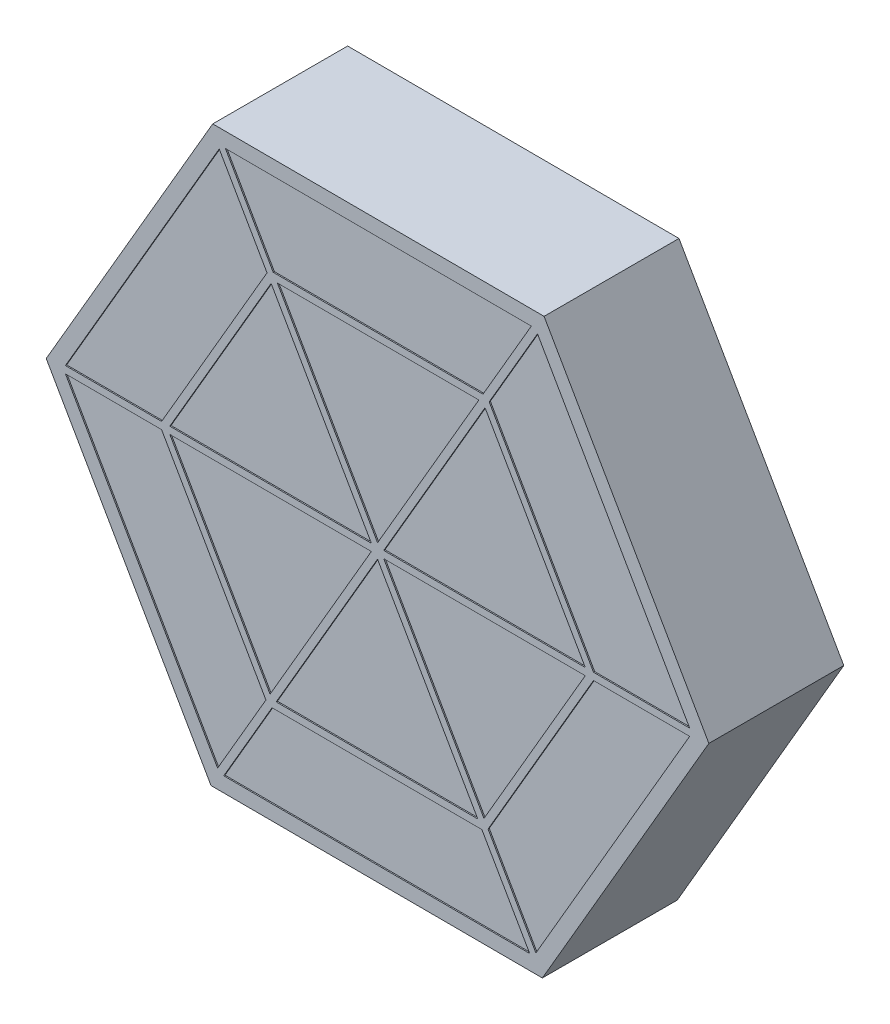
from build123d import *

# Parameters (mm, degrees)
SALIENTE_EXTRUIR1_DEPTH = 40
SALIENTE_EXTRUIR2_DEPTH = 5
SALIENTE_EXTRUIR3_DEPTH = 0.4


with BuildPart() as part:
    # Croquis1 → Saliente-Extruir1 (new body)
    with BuildSketch(Plane.XY):
        Polygon((-55.463005259, 96.735362128), (-111.506783676, 0.33530954), (-56.043778418, -96.400052588), (55.463005259, -96.735362128), (111.506783676, -0.33530954), (56.043778418, 96.400052588), align=None)
        Polygon((53.766067764, 92.51110391), (-53.233932236, 92.8183325), (-107, 0.30722859), (-53.766067764, -92.51110391), (53.233932236, -92.8183325), (107, -0.30722859), align=None, mode=Mode.SUBTRACT)
    extrude(amount=SALIENTE_EXTRUIR1_DEPTH)

    # Croquis2 → Saliente-Extruir2 (add)
    with BuildSketch(Plane.XY.offset(40)):
        Polygon((111.506783676, -0.33530954), (56.043778418, 96.400052588), (-55.463005259, 96.735362128), (-111.506783676, 0.33530954), (-56.043778418, -96.400052588), (55.463005259, -96.735362128), align=None)
    extrude(amount=SALIENTE_EXTRUIR2_DEPTH)

    # Croquis4 → Saliente-Extruir3 (add)
    with BuildSketch(Plane.XY.offset(45)):
        Polygon((-56.159430926, 95.537450908), (-110.810358009, 1.533220759), (-105.03688142, 1.515859468), (-53.287727951, 90.528792869), align=None)
        Polygon((-111.506783676, 0.33530954), (-110.817574962, -0.86676839), (-105.044098374, -0.884129681), (-105.733307088, 0.317948248), (-105.03688142, 1.515859468), (-110.810358009, 1.533220759), align=None)
        Polygon((-105.044098374, -0.884129681), (-110.817574962, -0.86676839), (-56.732987132, -95.197974658), (-53.831213518, -90.20667791), align=None)
        Polygon((-105.733307088, 0.317948248), (-105.044098374, -0.884129681), (-72.68406869, -0.981438798), (-73.373277404, 0.220639131), (-72.676851737, 1.418550351), (-105.03688142, 1.515859468), align=None)
        Polygon((-55.463005259, 96.735362128), (-56.159430926, 95.537450908), (-53.287727951, 90.528792869), (-52.591302284, 91.726704088), (-51.205667902, 91.722537378), (-54.077370877, 96.731195418), align=None)
        Polygon((54.658144036, 96.404219298), (-54.077370877, 96.731195418), (-51.205667902, 91.722537378), (51.756370423, 91.41292255), align=None)
        Polygon((-52.591302284, 91.726704088), (-53.287727951, 90.528792869), (-37.191985277, 62.455530537), (-36.495559609, 63.653441757), (-35.109925228, 63.649275047), (-51.205667902, 91.722537378), align=None)
        Polygon((56.043778418, 96.400052588), (54.658144036, 96.404219298), (51.756370423, 91.41292255), (53.142004804, 91.40875584), (53.831213518, 90.20667791), (56.732987132, 95.197974658), align=None)
        Polygon((53.142004804, 91.40875584), (51.756370423, 91.41292255), (35.492083414, 63.436969335), (36.877717795, 63.432802625), (37.566926509, 62.230724696), (53.831213518, 90.20667791), align=None)
        Polygon((110.817574962, 0.86676839), (56.732987132, 95.197974658), (53.831213518, 90.20667791), (105.044098374, 0.884129681), align=None)
        Polygon((72.676851737, -1.418550351), (105.03688142, -1.515859468), (105.733307088, -0.317948248), (105.044098374, 0.884129681), (72.68406869, 0.981438798), (73.373277404, -0.220639131), align=None)
        Polygon((105.03688142, -1.515859468), (110.810358009, -1.533220759), (111.506783676, -0.33530954), (110.817574962, 0.86676839), (105.044098374, 0.884129681), (105.733307088, -0.317948248), align=None)
        Polygon((53.287727951, -90.528792869), (56.159430926, -95.537450908), (110.810358009, -1.533220759), (105.03688142, -1.515859468), align=None)
        Polygon((-53.831213518, -90.20667791), (-56.732987132, -95.197974658), (-56.043778418, -96.400052588), (-54.658144036, -96.404219298), (-51.756370423, -91.41292255), (-53.142004804, -91.40875584), align=None)
        Polygon((-51.756370423, -91.41292255), (-54.658144036, -96.404219298), (54.077370877, -96.731195418), (51.205667902, -91.722537378), align=None)
        Polygon((51.205667902, -91.722537378), (54.077370877, -96.731195418), (55.463005259, -96.735362128), (56.159430926, -95.537450908), (53.287727951, -90.528792869), (52.591302284, -91.726704088), align=None)
        Polygon((35.109925228, -63.649275047), (51.205667902, -91.722537378), (52.591302284, -91.726704088), (53.287727951, -90.528792869), (37.191985277, -62.455530537), (36.495559609, -63.653441757), align=None)
        Polygon((-37.566926509, -62.230724696), (-53.831213518, -90.20667791), (-53.142004804, -91.40875584), (-51.756370423, -91.41292255), (-35.492083414, -63.436969335), (-36.877717795, -63.432802625), align=None)
        Polygon((-36.174075174, -59.834902257), (-37.566926509, -62.230724696), (-36.877717795, -63.432802625), (-35.492083414, -63.436969335), (-34.099232079, -61.041146896), (-35.48486646, -61.036980186), align=None)
        Polygon((-34.099232079, -61.041146896), (-35.492083414, -63.436969335), (35.109925228, -63.649275047), (33.7315078, -61.245119188), align=None)
        Polygon((-69.912799928, -0.989772218), (-72.68406869, -0.981438798), (-37.566926509, -62.230724696), (-36.174075174, -59.834902257), align=None)
        Polygon((33.7315078, -61.245119188), (35.109925228, -63.649275047), (36.495559609, -63.653441757), (37.191985277, -62.455530537), (35.813567849, -60.051374678), (35.117142181, -61.249285898), align=None)
        Polygon((2.074843095, -1.206244639), (0.689208714, -1.20207793), (-0.007216953, -2.399989149), (33.7315078, -61.245119188), (35.117142181, -61.249285898), (35.813567849, -60.051374678), align=None)
        Polygon((-0.696425667, -1.19791122), (-2.082060049, -1.19374451), (-36.174075174, -59.834902257), (-35.48486646, -61.036980186), (-34.099232079, -61.041146896), (-0.007216953, -2.399989149), align=None)
        Polygon((72.676851737, -1.418550351), (69.905582974, -1.410216931), (35.813567849, -60.051374678), (37.191985277, -62.455530537), align=None)
        Polygon((70.602008642, -0.212305711), (69.905582974, -1.410216931), (72.676851737, -1.418550351), (73.373277404, -0.220639131), (72.68406869, 0.981438798), (69.912799928, 0.989772218), align=None)
        Polygon((36.174075174, 59.834902257), (69.912799928, 0.989772218), (72.68406869, 0.981438798), (37.566926509, 62.230724696), align=None)
        Polygon((0.689208714, -1.20207793), (-0.696425667, -1.19791122), (-0.007216953, -2.399989149), align=None)
        Polygon((-1.385634381, 0.00416671), (-2.082060049, -1.19374451), (-0.696425667, -1.19791122), align=None)
        Polygon((-1.385634381, 0.00416671), (-0.696425667, -1.19791122), (0.689208714, -1.20207793), (1.385634381, -0.00416671), (0.696425667, 1.19791122), (-0.689208714, 1.20207793), align=None)
        Polygon((-2.074843095, 1.206244639), (-1.385634381, 0.00416671), (-0.689208714, 1.20207793), align=None)
        Polygon((0.007216953, 2.399989149), (-0.689208714, 1.20207793), (0.696425667, 1.19791122), align=None)
        Polygon((0.696425667, 1.19791122), (1.385634381, -0.00416671), (2.082060049, 1.19374451), align=None)
        Polygon((1.385634381, -0.00416671), (0.689208714, -1.20207793), (2.074843095, -1.206244639), align=None)
        Polygon((1.385634381, -0.00416671), (2.074843095, -1.206244639), (69.905582974, -1.410216931), (70.602008642, -0.212305711), (69.912799928, 0.989772218), (2.082060049, 1.19374451), align=None)
        Polygon((-70.602008642, 0.212305711), (-69.912799928, -0.989772218), (-2.082060049, -1.19374451), (-1.385634381, 0.00416671), (-2.074843095, 1.206244639), (-69.905582974, 1.410216931), align=None)
        Polygon((-35.813567849, 60.051374678), (-2.074843095, 1.206244639), (-0.689208714, 1.20207793), (0.007216953, 2.399989149), (-33.7315078, 61.245119188), (-35.117142181, 61.249285898), align=None)
        Polygon((0.007216953, 2.399989149), (0.696425667, 1.19791122), (2.082060049, 1.19374451), (36.174075174, 59.834902257), (35.48486646, 61.036980186), (34.099232079, 61.041146896), align=None)
        Polygon((35.492083414, 63.436969335), (34.099232079, 61.041146896), (35.48486646, 61.036980186), (36.174075174, 59.834902257), (37.566926509, 62.230724696), (36.877717795, 63.432802625), align=None)
        Polygon((35.492083414, 63.436969335), (-35.109925228, 63.649275047), (-33.7315078, 61.245119188), (34.099232079, 61.041146896), align=None)
        Polygon((-36.495559609, 63.653441757), (-37.191985277, 62.455530537), (-35.813567849, 60.051374678), (-35.117142181, 61.249285898), (-33.7315078, 61.245119188), (-35.109925228, 63.649275047), align=None)
        Polygon((-37.191985277, 62.455530537), (-72.676851737, 1.418550351), (-69.905582974, 1.410216931), (-35.813567849, 60.051374678), align=None)
        Polygon((-73.373277404, 0.220639131), (-72.68406869, -0.981438798), (-69.912799928, -0.989772218), (-70.602008642, 0.212305711), (-69.905582974, 1.410216931), (-72.676851737, 1.418550351), align=None)
    extrude(amount=SALIENTE_EXTRUIR3_DEPTH)


solid = part.part
